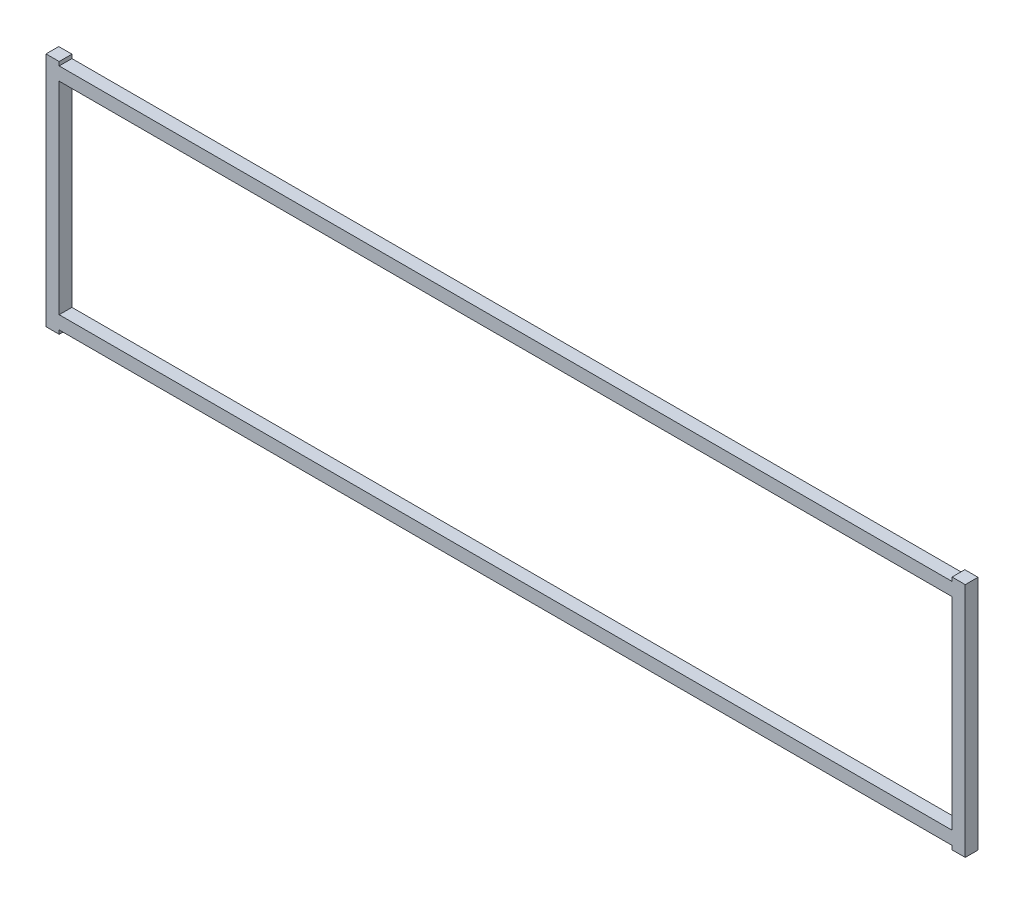
from build123d import *

# Parameters (mm, degrees)
SKETCH1_W           = 444.2968
SKETCH1_H           = 100.6475
BOSS_EXTRUDE1_DEPTH = 6.35


with BuildPart() as part:
    # Sketch1 → Boss-Extrude1 (new body)
    with BuildSketch(Plane.XY):
        Polygon((222.1484, -58.785125), (228.7016, -58.785125), (228.7016, 58.785125), (222.1484, 58.785125), (222.1484, 56.87695), (-222.1484, 56.87695), (-222.1484, 58.785125), (-228.7016, 58.785125), (-228.7016, -58.785125), (-222.1484, -58.785125), (-222.1484, -56.87695), (222.1484, -56.87695), align=None)
        Rectangle(SKETCH1_W, SKETCH1_H, mode=Mode.SUBTRACT)
    extrude(amount=BOSS_EXTRUDE1_DEPTH)


solid = part.part
